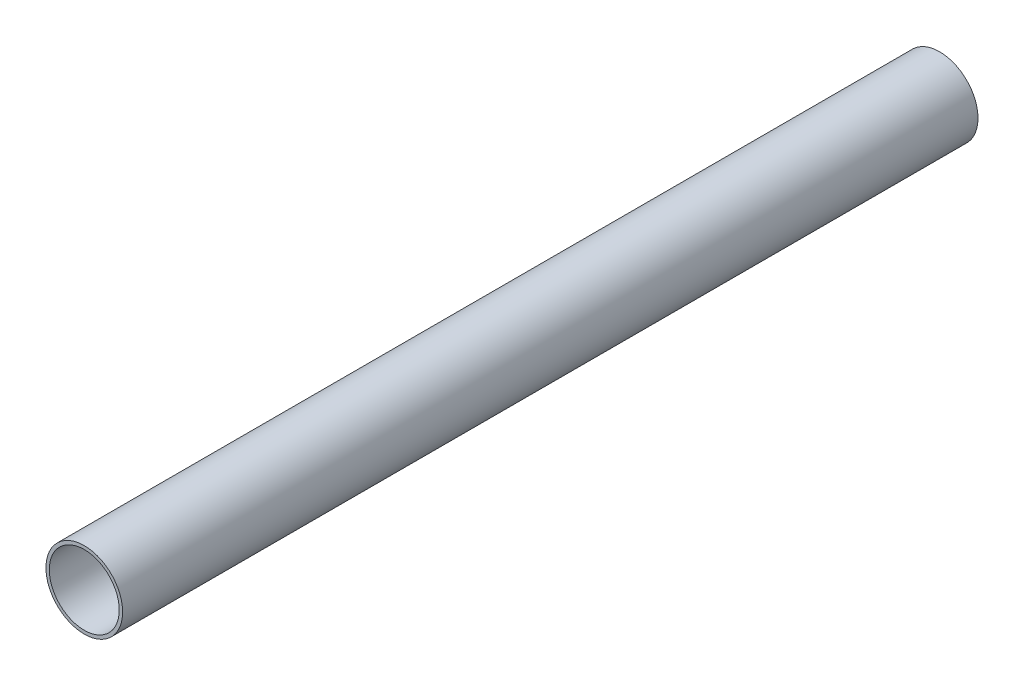
from build123d import *

# Parameters (mm, degrees)
SKETCH1_R           = 15.9385
SKETCH1_R_2         = 14.5415
BOSS_EXTRUDE1_DEPTH = 355.6


with BuildPart() as part:
    # Sketch1 → Boss-Extrude1 (new body)
    with BuildSketch(Plane.XY):
        Circle(SKETCH1_R)
        Circle(SKETCH1_R_2, mode=Mode.SUBTRACT)
    extrude(amount=BOSS_EXTRUDE1_DEPTH)


solid = part.part
